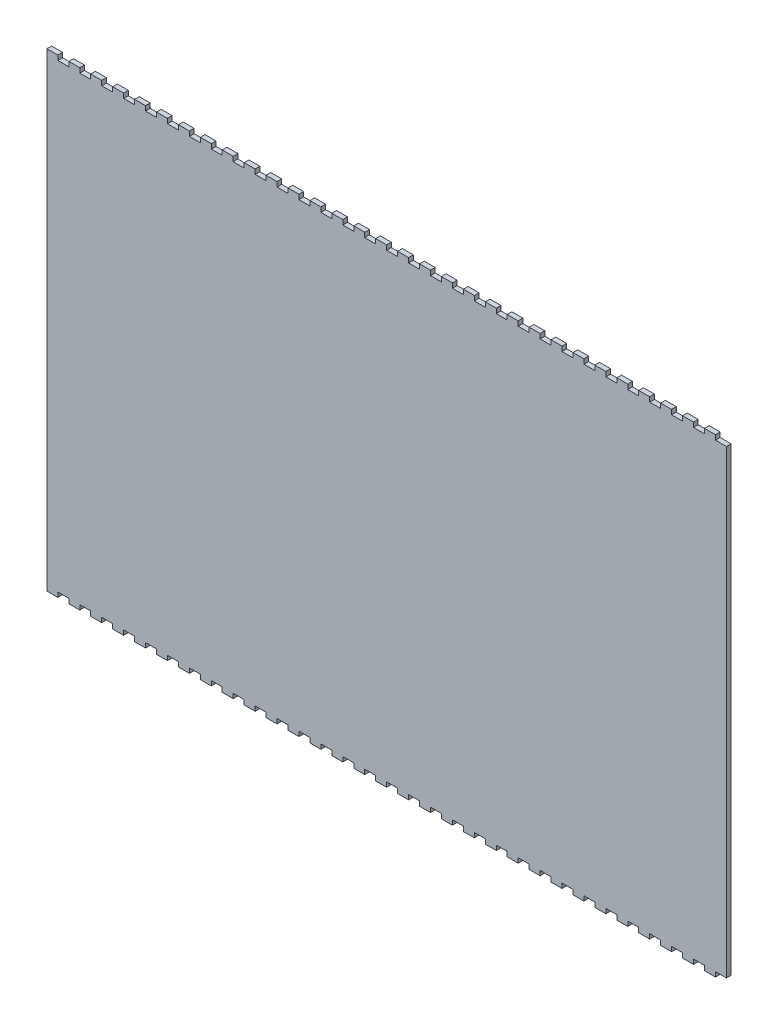
from build123d import *

# Parameters (mm, degrees)
ESQUISSE1_W             = 434
ESQUISSE1_H             = 300
BOSS_EXTRU_1_DEPTH      = 3
ESQUISSE2_W             = 7
ESQUISSE2_H             = 3
ENL_V_MAT_EXTRU_1_DEPTH = 3


with BuildPart() as part:
    # Esquisse1 → Boss.-Extru.1 (new body)
    with BuildSketch(Plane.XY):
        Rectangle(ESQUISSE1_W, ESQUISSE1_H)
    extrude(amount=BOSS_EXTRU_1_DEPTH)

    # Esquisse2 → Enlèv. mat.-Extru.1 (cut)
    with BuildSketch(Plane.XY.offset(3)):
        with Locations((-206.5, 148.5)):
            Rectangle(ESQUISSE2_W, ESQUISSE2_H)
        with Locations((-192.5, 148.5)):
            Rectangle(ESQUISSE2_W, ESQUISSE2_H)
        with Locations((-178.5, 148.5)):
            Rectangle(ESQUISSE2_W, ESQUISSE2_H)
        with Locations((-164.5, 148.5)):
            Rectangle(ESQUISSE2_W, ESQUISSE2_H)
        with Locations((-150.5, 148.5)):
            Rectangle(ESQUISSE2_W, ESQUISSE2_H)
        with Locations((-136.5, 148.5)):
            Rectangle(ESQUISSE2_W, ESQUISSE2_H)
        with Locations((-122.5, 148.5)):
            Rectangle(ESQUISSE2_W, ESQUISSE2_H)
        with Locations((-108.5, 148.5)):
            Rectangle(ESQUISSE2_W, ESQUISSE2_H)
        with Locations((-94.5, 148.5)):
            Rectangle(ESQUISSE2_W, ESQUISSE2_H)
        with Locations((-80.5, 148.5)):
            Rectangle(ESQUISSE2_W, ESQUISSE2_H)
        with Locations((-66.5, 148.5)):
            Rectangle(ESQUISSE2_W, ESQUISSE2_H)
        with Locations((-52.5, 148.5)):
            Rectangle(ESQUISSE2_W, ESQUISSE2_H)
        with Locations((-38.5, 148.5)):
            Rectangle(ESQUISSE2_W, ESQUISSE2_H)
        with Locations((-24.5, 148.5)):
            Rectangle(ESQUISSE2_W, ESQUISSE2_H)
        with Locations((-10.5, 148.5)):
            Rectangle(ESQUISSE2_W, ESQUISSE2_H)
        with Locations((3.5, 148.5)):
            Rectangle(ESQUISSE2_W, ESQUISSE2_H)
        with Locations((17.5, 148.5)):
            Rectangle(ESQUISSE2_W, ESQUISSE2_H)
        with Locations((31.5, 148.5)):
            Rectangle(ESQUISSE2_W, ESQUISSE2_H)
        with Locations((45.5, 148.5)):
            Rectangle(ESQUISSE2_W, ESQUISSE2_H)
        with Locations((59.5, 148.5)):
            Rectangle(ESQUISSE2_W, ESQUISSE2_H)
        with Locations((73.5, 148.5)):
            Rectangle(ESQUISSE2_W, ESQUISSE2_H)
        with Locations((87.5, 148.5)):
            Rectangle(ESQUISSE2_W, ESQUISSE2_H)
        with Locations((101.5, 148.5)):
            Rectangle(ESQUISSE2_W, ESQUISSE2_H)
        with Locations((115.5, 148.5)):
            Rectangle(ESQUISSE2_W, ESQUISSE2_H)
        with Locations((129.5, 148.5)):
            Rectangle(ESQUISSE2_W, ESQUISSE2_H)
        with Locations((143.5, 148.5)):
            Rectangle(ESQUISSE2_W, ESQUISSE2_H)
        with Locations((157.5, 148.5)):
            Rectangle(ESQUISSE2_W, ESQUISSE2_H)
        with Locations((171.5, 148.5)):
            Rectangle(ESQUISSE2_W, ESQUISSE2_H)
        with Locations((185.5, 148.5)):
            Rectangle(ESQUISSE2_W, ESQUISSE2_H)
        with Locations((199.5, 148.5)):
            Rectangle(ESQUISSE2_W, ESQUISSE2_H)
        with Locations((213.5, 148.5)):
            Rectangle(ESQUISSE2_W, ESQUISSE2_H)
        with Locations((213.5, -148.5)):
            Rectangle(ESQUISSE2_W, ESQUISSE2_H)
        with Locations((199.5, -148.5)):
            Rectangle(ESQUISSE2_W, ESQUISSE2_H)
        with Locations((185.5, -148.5)):
            Rectangle(ESQUISSE2_W, ESQUISSE2_H)
        with Locations((171.5, -148.5)):
            Rectangle(ESQUISSE2_W, ESQUISSE2_H)
        with Locations((157.5, -148.5)):
            Rectangle(ESQUISSE2_W, ESQUISSE2_H)
        with Locations((143.5, -148.5)):
            Rectangle(ESQUISSE2_W, ESQUISSE2_H)
        with Locations((129.5, -148.5)):
            Rectangle(ESQUISSE2_W, ESQUISSE2_H)
        with Locations((115.5, -148.5)):
            Rectangle(ESQUISSE2_W, ESQUISSE2_H)
        with Locations((101.5, -148.5)):
            Rectangle(ESQUISSE2_W, ESQUISSE2_H)
        with Locations((87.5, -148.5)):
            Rectangle(ESQUISSE2_W, ESQUISSE2_H)
        with Locations((73.5, -148.5)):
            Rectangle(ESQUISSE2_W, ESQUISSE2_H)
        with Locations((59.5, -148.5)):
            Rectangle(ESQUISSE2_W, ESQUISSE2_H)
        with Locations((45.5, -148.5)):
            Rectangle(ESQUISSE2_W, ESQUISSE2_H)
        with Locations((31.5, -148.5)):
            Rectangle(ESQUISSE2_W, ESQUISSE2_H)
        with Locations((17.5, -148.5)):
            Rectangle(ESQUISSE2_W, ESQUISSE2_H)
        with Locations((3.5, -148.5)):
            Rectangle(ESQUISSE2_W, ESQUISSE2_H)
        with Locations((-10.5, -148.5)):
            Rectangle(ESQUISSE2_W, ESQUISSE2_H)
        with Locations((-24.5, -148.5)):
            Rectangle(ESQUISSE2_W, ESQUISSE2_H)
        with Locations((-38.5, -148.5)):
            Rectangle(ESQUISSE2_W, ESQUISSE2_H)
        with Locations((-52.5, -148.5)):
            Rectangle(ESQUISSE2_W, ESQUISSE2_H)
        with Locations((-66.5, -148.5)):
            Rectangle(ESQUISSE2_W, ESQUISSE2_H)
        with Locations((-80.5, -148.5)):
            Rectangle(ESQUISSE2_W, ESQUISSE2_H)
        with Locations((-94.5, -148.5)):
            Rectangle(ESQUISSE2_W, ESQUISSE2_H)
        with Locations((-108.5, -148.5)):
            Rectangle(ESQUISSE2_W, ESQUISSE2_H)
        with Locations((-122.5, -148.5)):
            Rectangle(ESQUISSE2_W, ESQUISSE2_H)
        with Locations((-136.5, -148.5)):
            Rectangle(ESQUISSE2_W, ESQUISSE2_H)
        with Locations((-150.5, -148.5)):
            Rectangle(ESQUISSE2_W, ESQUISSE2_H)
        with Locations((-164.5, -148.5)):
            Rectangle(ESQUISSE2_W, ESQUISSE2_H)
        with Locations((-178.5, -148.5)):
            Rectangle(ESQUISSE2_W, ESQUISSE2_H)
        with Locations((-192.5, -148.5)):
            Rectangle(ESQUISSE2_W, ESQUISSE2_H)
        with Locations((-206.5, -148.5)):
            Rectangle(ESQUISSE2_W, ESQUISSE2_H)
    extrude(amount=-ENL_V_MAT_EXTRU_1_DEPTH, mode=Mode.SUBTRACT)


solid = part.part
